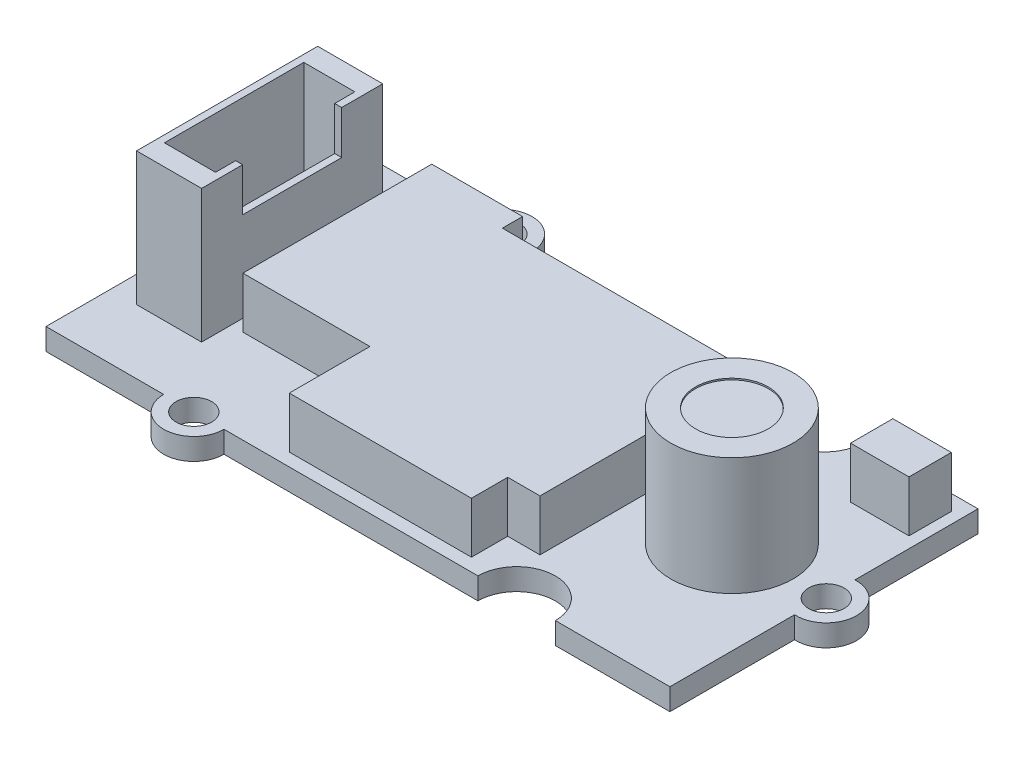
from build123d import *

# Parameters (mm, degrees)
SKETCH1_R           = 1.15
BOSS_EXTRUDE1_DEPTH = 1.4
BOSS_EXTRUDE2_START = -1.4
SKETCH2_R           = 3.95
BOSS_EXTRUDE2_DEPTH = 9
SKETCH3_W           = 4.2
SKETCH3_H           = 11.7
BOSS_EXTRUDE4_DEPTH = 8.6
SKETCH4_W           = 3.3
SKETCH4_H           = 9
CUT_EXTRUDE1_DEPTH  = 7
SKETCH5_W           = 0.45
SKETCH5_H           = 6.4
CUT_EXTRUDE2_DEPTH  = 2.8
SKETCH6_W           = 3.777009852
SKETCH6_H           = 2.7350761
BOSS_EXTRUDE6_DEPTH = 3.3
SKETCH7_W           = 4.5
SKETCH7_H           = 4.5
BOSS_EXTRUDE7_DEPTH = 1.1
SKETCH8_R           = 2.35
CUT_EXTRUDE3_DEPTH  = 0.1


with BuildPart() as part:
    # Sketch1 → Boss-Extrude1 (new body)
    with BuildSketch(Plane(origin=(0, 0, 0), x_dir=(1, 0, 0), z_dir=(0, 1, 0))):
        with BuildLine():
            Line((25.738550612, -3.990919322), (25.738550612, -12.04368231))
            Line((25.738550612, -12.04368231), (18.338550612, -12.04368231))
            ThreePointArc((18.338550612, -12.04368231), (15.838550612, -9.54368231), (13.338550612, -12.04368231))
            Line((13.338550612, -12.04368231), (-3.061449388, -12.04368231))
            ThreePointArc((-3.061449388, -12.04368231), (-5.011449388, -13.99368231), (-6.961449388, -12.04368231))
            Line((-6.961449388, -12.04368231), (-14.561449388, -12.04368231))
            Line((-14.561449388, -12.04368231), (-14.561449388, -4.543434765))
            ThreePointArc((-14.561449388, -4.543434765), (-12.096629884, -2.04368231), (-14.561449388, 0.456070144))
            Line((-14.561449388, 0.456070144), (-14.561449388, 7.85631769))
            Line((-14.561449388, 7.85631769), (-6.961449388, 7.85631769))
            ThreePointArc((-6.961449388, 7.85631769), (-5.011449388, 9.80631769), (-3.061449388, 7.85631769))
            Line((-3.061449388, 7.85631769), (13.338550612, 7.85631769))
            ThreePointArc((13.338550612, 7.85631769), (15.838550612, 5.35631769), (18.338550612, 7.85631769))
            Line((18.338550612, 7.85631769), (25.738550612, 7.85631769))
            Line((25.738550612, 7.85631769), (25.738550612, -0.096445299))
            ThreePointArc((25.738550612, -0.096445299), (27.792319693, -2.04368231), (25.738550612, -3.990919322))
        make_face()
        with Locations((25.842319693, -2.04368231)):
            Circle(SKETCH1_R, mode=Mode.SUBTRACT)
        with Locations((-5.011449388, -12.04368231)):
            Circle(SKETCH1_R, mode=Mode.SUBTRACT)
        with Locations((-5.011449388, 7.85631769)):
            Circle(SKETCH1_R, mode=Mode.SUBTRACT)
    extrude(amount=BOSS_EXTRUDE1_DEPTH)

    # Sketch2 → Boss-Extrude2 (add)
    with BuildSketch(Plane(origin=(0, 1.4, 0), x_dir=(1, 0, 0), z_dir=(0, 1, 0)).offset(BOSS_EXTRUDE2_START)):
        with Locations((19.742319693, -2.04368231)):
            Circle(SKETCH2_R)
    extrude(amount=BOSS_EXTRUDE2_DEPTH)

    # Sketch3 → Boss-Extrude4 (add)
    with BuildSketch(Plane(origin=(0, 1.4, 0), x_dir=(1, 0, 0), z_dir=(0, 1, 0))):
        with Locations((-10.761449388, -2.04368231)):
            Rectangle(SKETCH3_W, SKETCH3_H)
    extrude(amount=BOSS_EXTRUDE4_DEPTH)

    # Sketch4 → Cut-Extrude1 (cut)
    with BuildSketch(Plane(origin=(0, 10, 0), x_dir=(1, 0, 0), z_dir=(0, 1, 0))):
        with Locations((-10.761449388, -2.04368231)):
            Rectangle(SKETCH4_W, SKETCH4_H)
    extrude(amount=-CUT_EXTRUDE1_DEPTH, mode=Mode.SUBTRACT)

    # Sketch5 → Cut-Extrude2 (cut)
    with BuildSketch(Plane(origin=(0, 10, 0), x_dir=(1, 0, 0), z_dir=(0, 1, 0))):
        with Locations((-8.886449388, -2.04368231)):
            Rectangle(SKETCH5_W, SKETCH5_H)
    extrude(amount=-CUT_EXTRUDE2_DEPTH, mode=Mode.SUBTRACT)

    # Sketch6 → Boss-Extrude6 (add)
    with BuildSketch(Plane(origin=(0, 1.4, 0), x_dir=(1, 0, 0), z_dir=(0, 1, 0))):
        Polygon((-7.884809568, 6.198373802), (-2.023932211, 6.198373802), (-2.023932211, 4.895956612), (17.251842208, 4.895956612), (17.251842208, 1.987224886), (14.169454857, 1.987224886), (14.169454857, -8.866251701), (12.085587353, -8.866251701), (12.085587353, -11.210602644), (0.320418732, -11.210602644), (0.320418732, -6.000933882), (-7.884809568, -6.000933882), align=None)
        with Locations((23.134426518, 5.482044347)):
            Rectangle(SKETCH6_W, SKETCH6_H)
    extrude(amount=BOSS_EXTRUDE6_DEPTH)

    # Sketch7 → Boss-Extrude7 (add)
    with BuildSketch(Plane.XZ):
        with Locations((20.088550612, 2.04368231)):
            Rectangle(SKETCH7_W, SKETCH7_H)
    extrude(amount=BOSS_EXTRUDE7_DEPTH)

    # Sketch8 → Cut-Extrude3 (cut)
    with BuildSketch(Plane(origin=(0, 9, 0), x_dir=(1, 0, 0), z_dir=(0, 1, 0))):
        with Locations((19.742319693, -2.04368231)):
            Circle(SKETCH8_R)
    extrude(amount=-CUT_EXTRUDE3_DEPTH, mode=Mode.SUBTRACT)


solid = part.part
